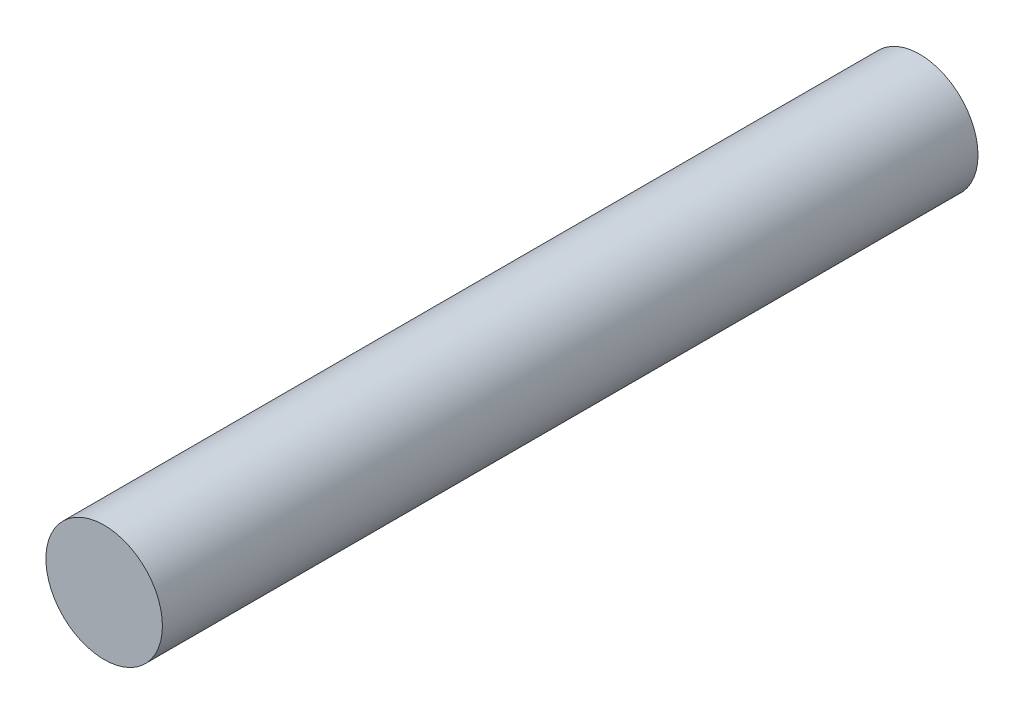
from build123d import *

# Parameters (mm, degrees)
SKETCH1_R           = 2.5
BOSS_EXTRUDE1_DEPTH = 35


with BuildPart() as part:
    # Sketch1 → Boss-Extrude1 (new body)
    with BuildSketch(Plane.XY):
        Circle(SKETCH1_R)
    extrude(amount=BOSS_EXTRUDE1_DEPTH)


solid = part.part
